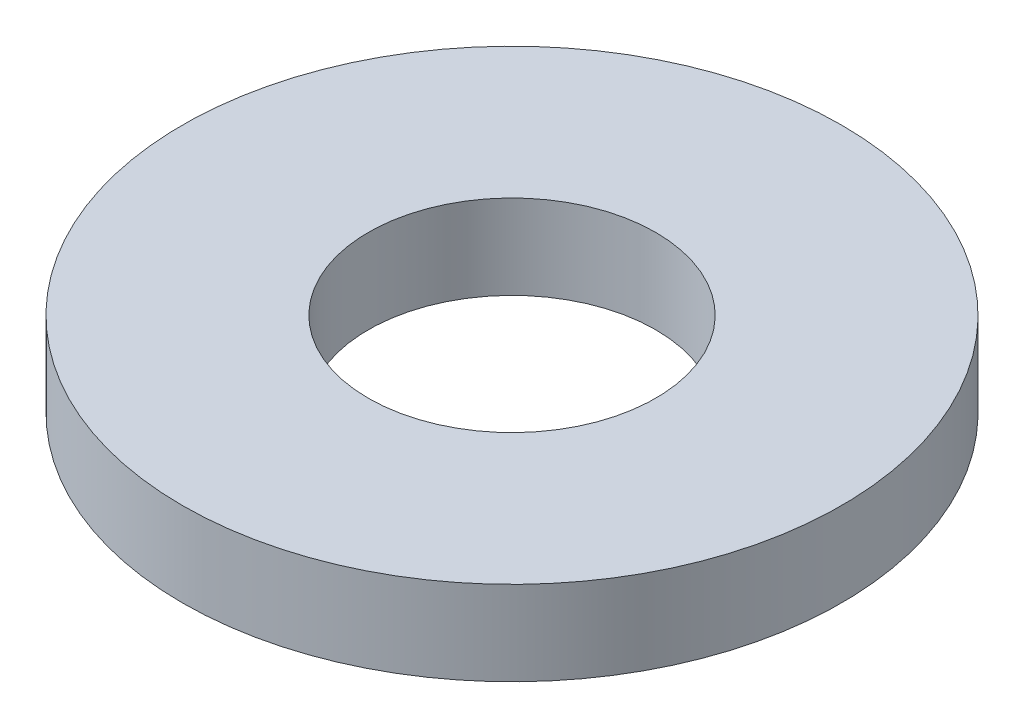
from build123d import *

# Parameters (mm, degrees)
SKETCH1_R           = 3.175
BOSS_EXTRUDE1_DEPTH = 0.8128
SKETCH5_R           = 1.3843
CUT_EXTRUDE1_DEPTH  = 1.8128


with BuildPart() as part:
    # Sketch1 → Boss-Extrude1 (new body)
    with BuildSketch(Plane(origin=(0, 0, 0), x_dir=(1, 0, 0), z_dir=(0, 1, 0))):
        Circle(SKETCH1_R)
    extrude(amount=BOSS_EXTRUDE1_DEPTH)

    # Sketch5 → Cut-Extrude1 (cut, through all)
    with BuildSketch(Plane(origin=(0, 0.8128, 0), x_dir=(-1, 0, 0), z_dir=(0, 1, 0))):
        Circle(SKETCH5_R)
    extrude(amount=-CUT_EXTRUDE1_DEPTH, mode=Mode.SUBTRACT)


solid = part.part
